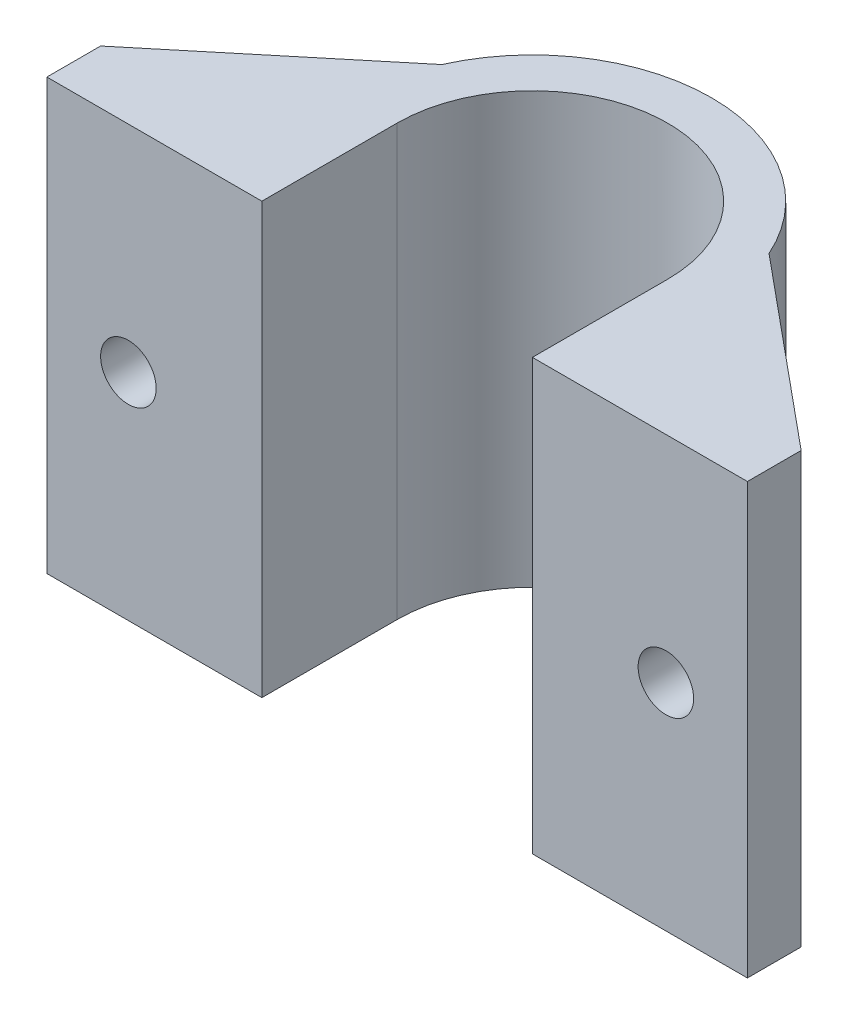
from build123d import *

# Parameters (mm, degrees)
SALIENTE_EXTRUIR1_DEPTH = 24
CROQUIS3_R              = 1.55
CORTAR_EXTRUIR1_DEPTH   = 18.55
CORTAR_EXTRUIR2_DEPTH   = 17
CORTAR_EXTRUIR3_DEPTH   = 17


with BuildPart() as part:
    # Croquis2 → Saliente-Extruir1 (new body)
    with BuildSketch(Plane(origin=(0, 0, 0), x_dir=(1, 0, 0), z_dir=(0, 1, 0))):
        with BuildLine():
            Line((-7.55, 0), (-7.55, -7.55))
            Line((-7.55, -7.55), (-19.55, -7.55))
            Line((-19.55, -7.55), (-19.55, -4.55))
            Line((-19.55, -4.55), (-9.131754542, 4.075666691))
            ThreePointArc((-9.131754542, 4.075666691), (-2e-09, 10), (9.131754541, 4.075666695))
            Line((9.131754541, 4.075666695), (19.55, -4.55))
            Line((19.55, -4.55), (19.55, -7.55))
            Line((19.55, -7.55), (7.55, -7.55))
            Line((7.55, -7.55), (7.55, 0))
            ThreePointArc((7.55, 0), (0, 7.55), (-7.55, 0))
        make_face()
    extrude(amount=SALIENTE_EXTRUIR1_DEPTH)

    # Croquis3 → Cortar-Extruir1 (cut, through all)
    with BuildSketch(Plane.XY.offset(7.55)):
        with Locations((15, 12)):
            Circle(CROQUIS3_R)
        with Locations((-15, 12)):
            Circle(CROQUIS3_R)
    extrude(amount=-CORTAR_EXTRUIR1_DEPTH, mode=Mode.SUBTRACT)

    # Croquis4 → Cortar-Extruir2 (cut)
    with BuildSketch(Plane(origin=(0, 21, 0), x_dir=(1, 0, 0), z_dir=(0, 1, 0))):
        Polygon((-9.131754542, 4.075666691), (-19.55, -4.55), (-9.131754542, -4.55), align=None)
    extrude(amount=-CORTAR_EXTRUIR2_DEPTH, mode=Mode.SUBTRACT)

    # Croquis5 → Cortar-Extruir3 (cut)
    with BuildSketch(Plane(origin=(0, 21, 0), x_dir=(1, 0, 0), z_dir=(0, 1, 0))):
        Polygon((19.55, -4.55), (9.131754541, 4.075666695), (9.131754541, -4.55), align=None)
    extrude(amount=-CORTAR_EXTRUIR3_DEPTH, mode=Mode.SUBTRACT)


solid = part.part
